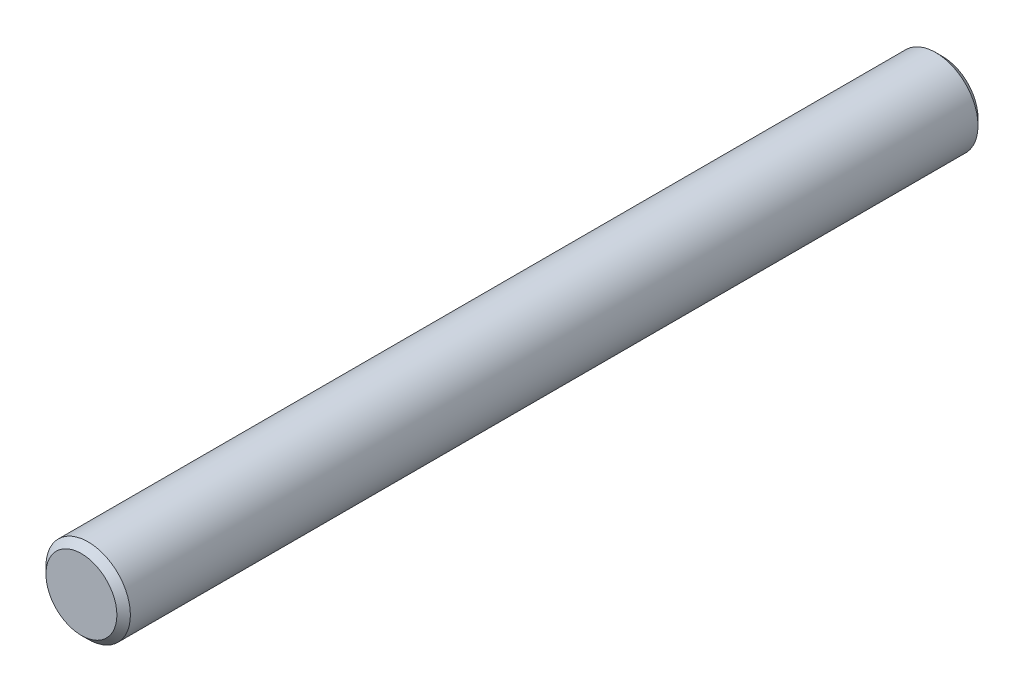
from build123d import *

# Parameters (mm, degrees)
SKETCH1_R           = 2.38125
BOSS_EXTRUDE1_DEPTH = 48.560000034
CHAMFER1_SIZE       = 0.381


with BuildPart() as part:
    # Sketch1 → Boss-Extrude1 (new body)
    with BuildSketch(Plane.XY):
        Circle(SKETCH1_R)
    extrude(amount=BOSS_EXTRUDE1_DEPTH)

    # Chamfer1
    chamfer1_edges = [part.edges().sort_by_distance(p)[0] for p in [
        (-2.38125, 0, 0),
        (-2.38125, 0, 48.560000034),
    ]]
    chamfer(chamfer1_edges, length=CHAMFER1_SIZE)


solid = part.part
